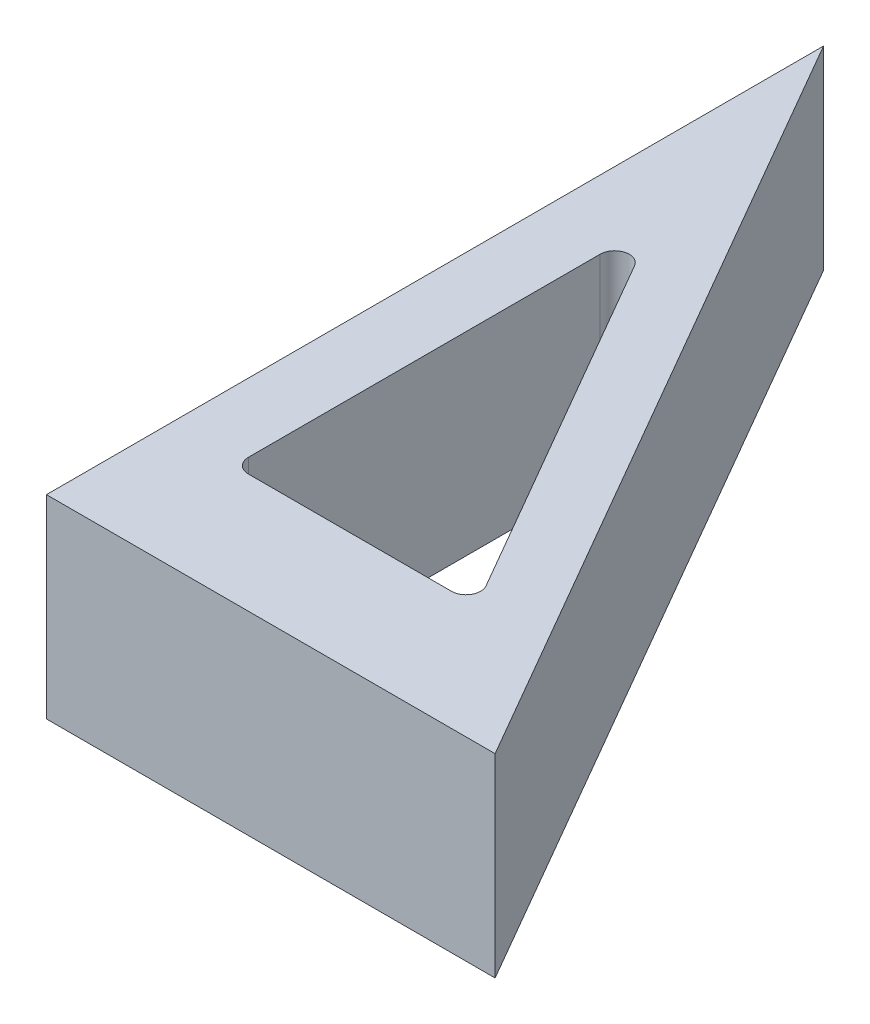
from build123d import *

# Parameters (mm, degrees)
BOSS_EXTRUDE1_DEPTH = 20
CUT_EXTRUDE1_DEPTH  = 21
FILLET1_R           = 1.5


with BuildPart() as part:
    # Sketch1 → Boss-Extrude1 (new body)
    with BuildSketch(Plane(origin=(0, 0, 0), x_dir=(1, 0, 0), z_dir=(0, 1, 0))):
        Polygon((0, 0), (0, 80), (46.188021535, 0), align=None)
    extrude(amount=BOSS_EXTRUDE1_DEPTH)

    # Sketch2 → Cut-Extrude1 (cut, through all)
    with BuildSketch(Plane(origin=(0, 20, 0), x_dir=(1, 0, 0), z_dir=(0, 1, 0))):
        Polygon((7.062673845, 55.534180126), (7.062673845, 12.232909937), (32.062673845, 12.232909937), align=None)
    extrude(amount=-CUT_EXTRUDE1_DEPTH, mode=Mode.SUBTRACT)

    # Fillet1
    fillet1_edges = [part.edges().sort_by_distance(p)[0] for p in [
        (7.062673845, 10, -55.534180126),
        (32.062673845, 10, -12.232909937),
        (7.062673845, 10, -12.232909937),
    ]]
    fillet(fillet1_edges, radius=FILLET1_R)


solid = part.part
